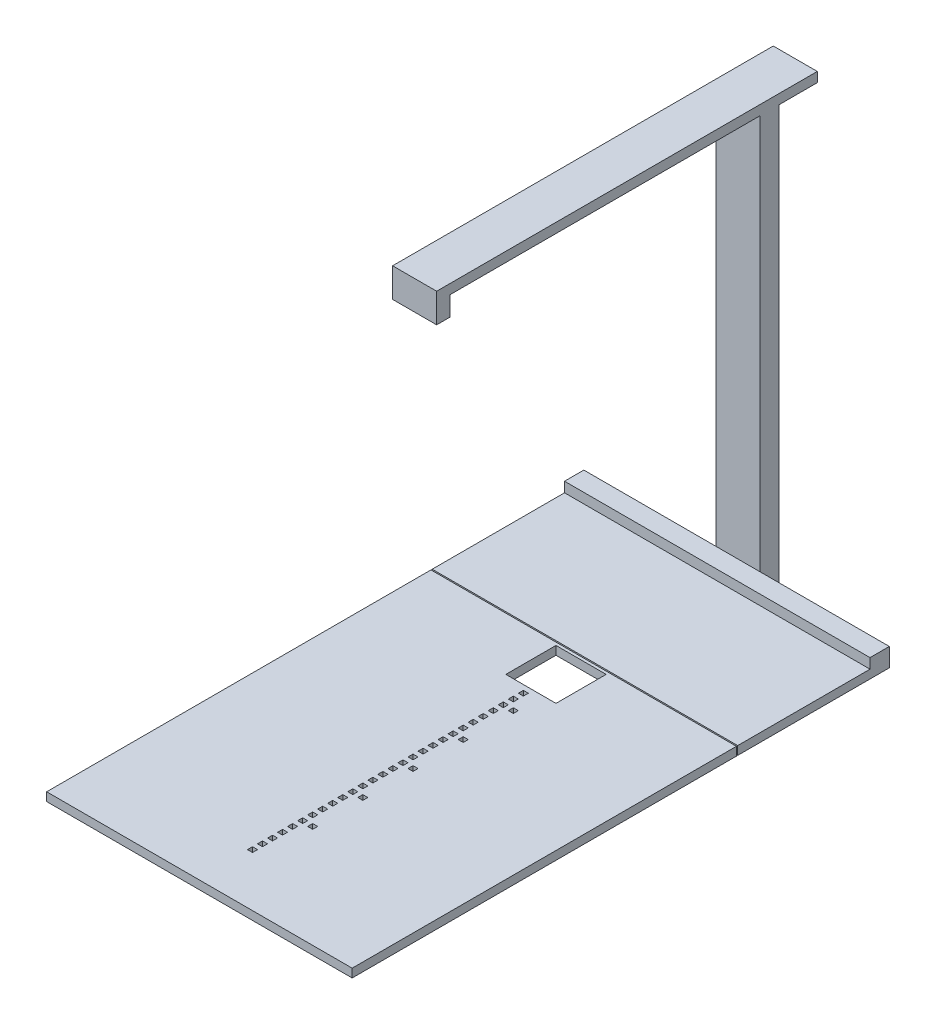
from build123d import *

# Parameters (mm, degrees)
SKETCH1_W           = 609
SKETCH1_H           = 766
SKETCH1_W_2         = 10
SKETCH1_H_2         = 10
SKETCH1_W_3         = 100
SKETCH1_H_3         = 100
BOSS_EXTRUDE1_DEPTH = 17
SKETCH2_W           = 609
SKETCH2_H           = 302.26
BOSS_EXTRUDE2_DEPTH = 17
SKETCH3_W           = 609
SKETCH3_H           = 38.5
BOSS_EXTRUDE3_DEPTH = 20
SKETCH4_W           = 87.8
SKETCH4_H           = 37.9
BOSS_EXTRUDE4_DEPTH = 824.4
SKETCH5_W           = 87.8
SKETCH5_H           = 758.825
BOSS_EXTRUDE5_DEPTH = 19.4
SKETCH6_W           = 87.8
SKETCH6_H           = 27
BOSS_EXTRUDE6_DEPTH = 38.7


with BuildPart() as part:
    # Sketch1 → Boss-Extrude1 (new body)
    with BuildSketch(Plane(origin=(0, 0, 0), x_dir=(1, 0, 0), z_dir=(0, 1, 0))):
        with Locations((-0.5, -327.27)):
            Rectangle(SKETCH1_W, SKETCH1_H)
        with Locations((0, -85)):
            Rectangle(SKETCH1_W_2, SKETCH1_H_2, mode=Mode.SUBTRACT)
        Rectangle(SKETCH1_W_3, SKETCH1_H_3, mode=Mode.SUBTRACT)
        with Locations((0, -65)):
            Rectangle(SKETCH1_W_2, SKETCH1_H_2, mode=Mode.SUBTRACT)
        with Locations((0, -105)):
            Rectangle(SKETCH1_W_2, SKETCH1_H_2, mode=Mode.SUBTRACT)
        with Locations((0, -125)):
            Rectangle(SKETCH1_W_2, SKETCH1_H_2, mode=Mode.SUBTRACT)
        with Locations((0, -145)):
            Rectangle(SKETCH1_W_2, SKETCH1_H_2, mode=Mode.SUBTRACT)
        with Locations((0, -165)):
            Rectangle(SKETCH1_W_2, SKETCH1_H_2, mode=Mode.SUBTRACT)
        with Locations((0, -185)):
            Rectangle(SKETCH1_W_2, SKETCH1_H_2, mode=Mode.SUBTRACT)
        with Locations((0, -205)):
            Rectangle(SKETCH1_W_2, SKETCH1_H_2, mode=Mode.SUBTRACT)
        with Locations((0, -225)):
            Rectangle(SKETCH1_W_2, SKETCH1_H_2, mode=Mode.SUBTRACT)
        with Locations((0, -245)):
            Rectangle(SKETCH1_W_2, SKETCH1_H_2, mode=Mode.SUBTRACT)
        with Locations((0, -265)):
            Rectangle(SKETCH1_W_2, SKETCH1_H_2, mode=Mode.SUBTRACT)
        with Locations((0, -285)):
            Rectangle(SKETCH1_W_2, SKETCH1_H_2, mode=Mode.SUBTRACT)
        with Locations((0, -305)):
            Rectangle(SKETCH1_W_2, SKETCH1_H_2, mode=Mode.SUBTRACT)
        with Locations((0, -325)):
            Rectangle(SKETCH1_W_2, SKETCH1_H_2, mode=Mode.SUBTRACT)
        with Locations((0, -345)):
            Rectangle(SKETCH1_W_2, SKETCH1_H_2, mode=Mode.SUBTRACT)
        with Locations((0, -365)):
            Rectangle(SKETCH1_W_2, SKETCH1_H_2, mode=Mode.SUBTRACT)
        with Locations((0, -385)):
            Rectangle(SKETCH1_W_2, SKETCH1_H_2, mode=Mode.SUBTRACT)
        with Locations((0, -405)):
            Rectangle(SKETCH1_W_2, SKETCH1_H_2, mode=Mode.SUBTRACT)
        with Locations((0, -425)):
            Rectangle(SKETCH1_W_2, SKETCH1_H_2, mode=Mode.SUBTRACT)
        with Locations((0, -445)):
            Rectangle(SKETCH1_W_2, SKETCH1_H_2, mode=Mode.SUBTRACT)
        with Locations((0, -465)):
            Rectangle(SKETCH1_W_2, SKETCH1_H_2, mode=Mode.SUBTRACT)
        with Locations((0, -485)):
            Rectangle(SKETCH1_W_2, SKETCH1_H_2, mode=Mode.SUBTRACT)
        with Locations((0, -505)):
            Rectangle(SKETCH1_W_2, SKETCH1_H_2, mode=Mode.SUBTRACT)
        with Locations((0, -525)):
            Rectangle(SKETCH1_W_2, SKETCH1_H_2, mode=Mode.SUBTRACT)
        with Locations((0, -545)):
            Rectangle(SKETCH1_W_2, SKETCH1_H_2, mode=Mode.SUBTRACT)
        with Locations((0, -565)):
            Rectangle(SKETCH1_W_2, SKETCH1_H_2, mode=Mode.SUBTRACT)
        with Locations((0, -585)):
            Rectangle(SKETCH1_W_2, SKETCH1_H_2, mode=Mode.SUBTRACT)
        with Locations((0, -605)):
            Rectangle(SKETCH1_W_2, SKETCH1_H_2, mode=Mode.SUBTRACT)
        with Locations((20, -105)):
            Rectangle(SKETCH1_W_2, SKETCH1_H_2, mode=Mode.SUBTRACT)
        with Locations((20, -205)):
            Rectangle(SKETCH1_W_2, SKETCH1_H_2, mode=Mode.SUBTRACT)
        with Locations((20, -305)):
            Rectangle(SKETCH1_W_2, SKETCH1_H_2, mode=Mode.SUBTRACT)
        with Locations((20, -405)):
            Rectangle(SKETCH1_W_2, SKETCH1_H_2, mode=Mode.SUBTRACT)
        with Locations((20, -505)):
            Rectangle(SKETCH1_W_2, SKETCH1_H_2, mode=Mode.SUBTRACT)
    extrude(amount=BOSS_EXTRUDE1_DEPTH)


with BuildPart() as body_2:
    # Sketch2 → Boss-Extrude2 (new body)
    with BuildSketch(Plane(origin=(0, 0, 0), x_dir=(-1, 0, 0), z_dir=(0, -1, 0))):
        with Locations((0.5, 209.4)):
            Rectangle(SKETCH2_W, SKETCH2_H)
    extrude(amount=-BOSS_EXTRUDE2_DEPTH)

    # Sketch3 → Boss-Extrude3 (add)
    with BuildSketch(Plane(origin=(0, 17, 0), x_dir=(1, 0, 0), z_dir=(0, 1, 0))):
        with Locations((-0.5, 341.28)):
            Rectangle(SKETCH3_W, SKETCH3_H)
    extrude(amount=BOSS_EXTRUDE3_DEPTH)

    # Sketch4 → Boss-Extrude4 (add)
    with BuildSketch(Plane.XZ):
        with Locations((2.425, -379.48)):
            Rectangle(SKETCH4_W, SKETCH4_H)
    extrude(amount=-BOSS_EXTRUDE4_DEPTH)

    # Sketch5 → Boss-Extrude5 (add)
    with BuildSketch(Plane(origin=(0, 824.4, 0), x_dir=(1, 0, 0), z_dir=(0, 1, 0))):
        with Locations((2.425, 95.2175)):
            Rectangle(SKETCH5_W, SKETCH5_H)
    extrude(amount=BOSS_EXTRUDE5_DEPTH)

    # Sketch6 → Boss-Extrude6 (add)
    with BuildSketch(Plane.XZ.offset(-824.4)):
        with Locations((2.425, 270.695)):
            Rectangle(SKETCH6_W, SKETCH6_H)
    extrude(amount=BOSS_EXTRUDE6_DEPTH)


solid = Compound([part.part, body_2.part])
